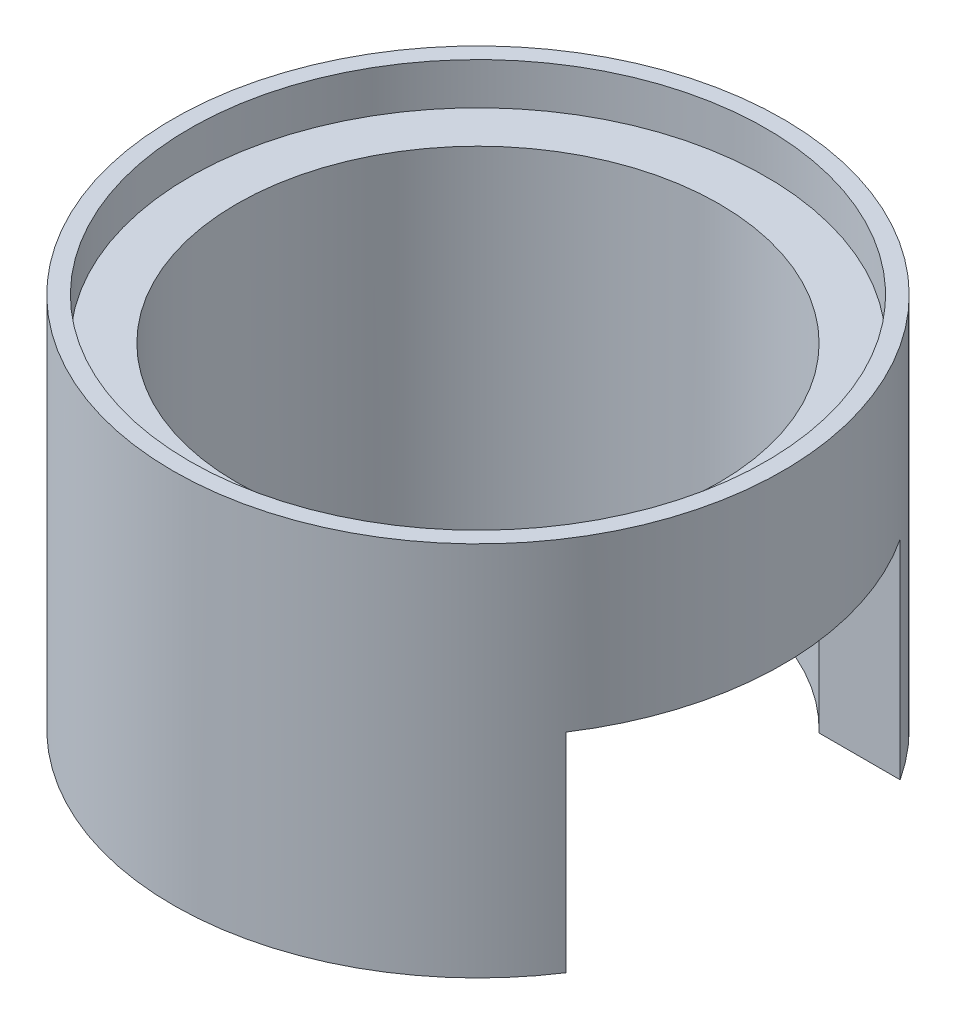
from build123d import *

# Parameters (mm, degrees)
SKETCH1_R           = 7.3
BOSS_EXTRUDE1_DEPTH = 9
SKETCH2_R           = 6.9
CUT_EXTRUDE1_DEPTH  = 1
SKETCH3_R           = 5
CUT_EXTRUDE2_DEPTH  = 7
SKETCH4_R           = 5.775
CUT_EXTRUDE3_DEPTH  = 9
SKETCH5_W           = 4
SKETCH5_H           = 4.989216575
CUT_EXTRUDE4_DEPTH  = 6


with BuildPart() as part:
    # Sketch1 → Boss-Extrude1 (new body)
    with BuildSketch(Plane(origin=(0, 0, 0), x_dir=(1, 0, 0), z_dir=(0, 1, 0))):
        Circle(SKETCH1_R)
    extrude(amount=BOSS_EXTRUDE1_DEPTH)

    # Sketch2 → Cut-Extrude1 (cut)
    with BuildSketch(Plane(origin=(0, 9, 0), x_dir=(1, 0, 0), z_dir=(0, 1, 0))):
        Circle(SKETCH2_R)
    extrude(amount=-CUT_EXTRUDE1_DEPTH, mode=Mode.SUBTRACT)

    # Sketch3 → Cut-Extrude2 (cut)
    with BuildSketch(Plane.XZ):
        Circle(SKETCH3_R)
    extrude(amount=-CUT_EXTRUDE2_DEPTH, mode=Mode.SUBTRACT)

    # Sketch4 → Cut-Extrude3 (cut, through all)
    with BuildSketch(Plane(origin=(0, 8, 0), x_dir=(1, 0, 0), z_dir=(0, 1, 0))):
        Circle(SKETCH4_R)
    extrude(amount=-CUT_EXTRUDE3_DEPTH, mode=Mode.SUBTRACT)

    # Sketch5 → Cut-Extrude4 (cut)
    with BuildSketch(Plane(origin=(7.3, 0, 0), x_dir=(0, 0, -1), z_dir=(1, 0, 0))):
        with Locations((-2, 2.494608288)):
            Rectangle(SKETCH5_W, SKETCH5_H)
        with Locations((2, 2.494608288)):
            Rectangle(SKETCH5_W, SKETCH5_H)
    extrude(amount=-CUT_EXTRUDE4_DEPTH, mode=Mode.SUBTRACT)


solid = part.part
